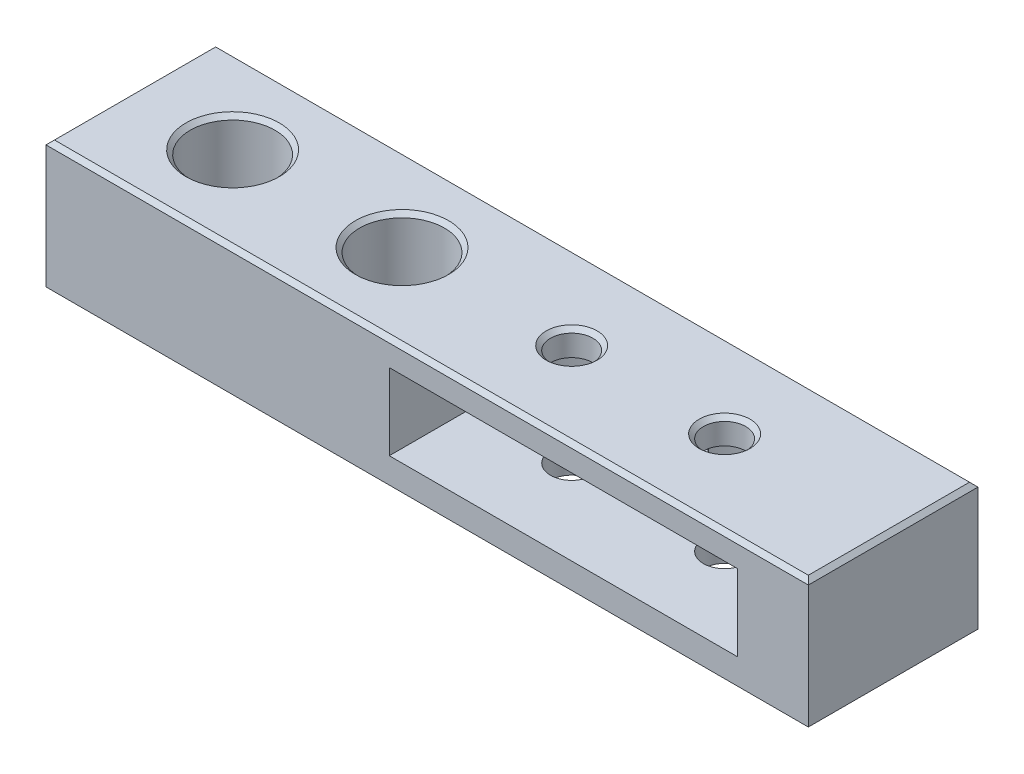
from build123d import *

# Parameters (mm, degrees)
SKETCH1_W                      = 81.37
SKETCH1_H                      = 20
SKETCH1_R                      = 2.5
BOSS_EXTRUDE1_DEPTH            = 15
CBORE_FOR_M5_SHCS1_D           = 5.5
CBORE_FOR_M5_SHCS1_CBORE_D     = 10
CBORE_FOR_M5_SHCS1_CBORE_DEPTH = 10
SKETCH8_W                      = 20
SKETCH8_H                      = 15
BOSS_EXTRUDE3_DEPTH            = 8.5
CUT_EXTRUDE1_START             = -3
CUT_EXTRUDE1_DEPTH             = 9
SKETCH7_W                      = 5
SKETCH7_H                      = 6.1
BOSS_EXTRUDE2_DEPTH            = 4
CHAMFER1_SIZE                  = 0.5


with BuildPart() as part:
    # Sketch1 → Boss-Extrude1 (new body)
    with BuildSketch(Plane(origin=(0, 0, 0), x_dir=(1, 0, 0), z_dir=(0, 1, 0))):
        with Locations((-29.315, 0)):
            Rectangle(SKETCH1_W, SKETCH1_H)
        Circle(SKETCH1_R, mode=Mode.SUBTRACT)
        with Locations((-18.03, 0)):
            Circle(SKETCH1_R, mode=Mode.SUBTRACT)
    extrude(amount=BOSS_EXTRUDE1_DEPTH)

    # CBORE for M5 SHCS1 (through all)
    with Locations(Plane(origin=(0, 15, 0), x_dir=(1, 0, 0), z_dir=(0, 1, 0))):
        with Locations((-58, 0), (-38.03, 0)):
            CounterBoreHole(CBORE_FOR_M5_SHCS1_D / 2, CBORE_FOR_M5_SHCS1_CBORE_D / 2, CBORE_FOR_M5_SHCS1_CBORE_DEPTH)

    # Sketch8 → Boss-Extrude3 (add)
    with BuildSketch(Plane(origin=(11.37, 0, 0), x_dir=(0, 0, -1), z_dir=(1, 0, 0))):
        with Locations((0, 7.5)):
            Rectangle(SKETCH8_W, SKETCH8_H)
    extrude(amount=BOSS_EXTRUDE3_DEPTH)

    # Sketch6 → Cut-Extrude1 (cut)
    with BuildSketch(Plane(origin=(0, 15, 0), x_dir=(1, 0, 0), z_dir=(0, 1, 0)).offset(CUT_EXTRUDE1_START)):
        with BuildLine():
            Line((-29.53, 0), (-29.53, -10))
            Line((-29.53, -10), (11.5, -10))
            Line((11.5, -10), (11.5, 0))
            ThreePointArc((11.5, 0), (3.780046296, 10.860996731), (-9.015, 7.140012255))
            ThreePointArc((-9.015, 7.140012255), (-21.810046296, 10.860996731), (-29.53, 0))
        make_face()
    extrude(amount=-CUT_EXTRUDE1_DEPTH, mode=Mode.SUBTRACT)

    # Sketch7 → Boss-Extrude2 (add)
    with BuildSketch(Plane.XZ):
        with Locations((-11.5, 0)):
            Rectangle(SKETCH7_W, SKETCH7_H)
        with Locations((-67.5, 0)):
            Rectangle(SKETCH7_W, SKETCH7_H)
    extrude(amount=BOSS_EXTRUDE2_DEPTH)

    # Chamfer1
    chamfer1_edges = [part.edges().sort_by_distance(p)[0] for p in [
        (-2.5, 15, 0),
        (-70, 15, 0),
        (-20.53, 15, 0),
        (-25.065, 15, 10),
        (-43.03, 15, 0),
        (-63, 15, 0),
        (19.87, 15, 0),
        (-25.065, 15, -10),
    ]]
    chamfer(chamfer1_edges, length=CHAMFER1_SIZE)


solid = part.part
